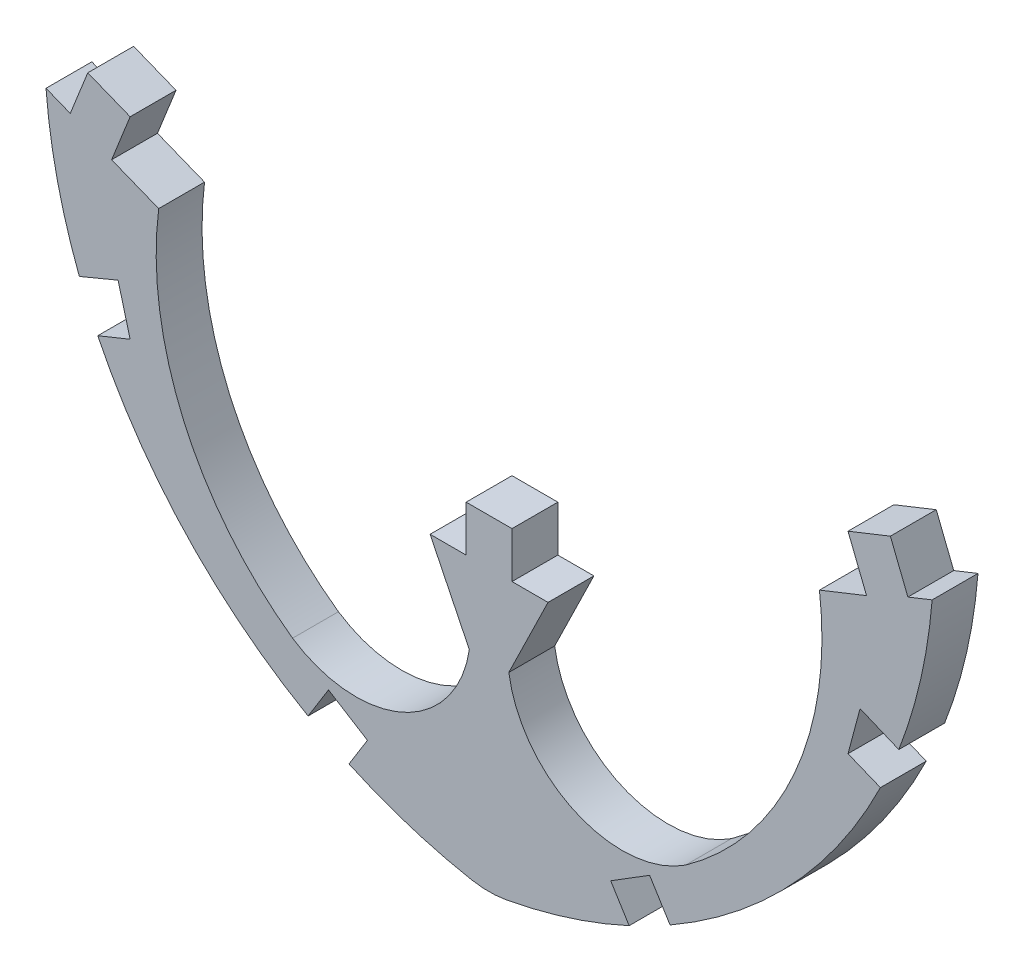
from build123d import *

# Parameters (mm, degrees)
BOSS_EXTRUDE1_DEPTH = 1.524


with BuildPart() as part:
    # Sketch1 → Boss-Extrude1 (new body)
    with BuildSketch(Plane.XY):
        with BuildLine():
            Line((106.800157748, 0), (106.800157748, -1.524))
            Line((106.800157748, -1.524), (105.60228421, -1.524))
            Line((105.60228421, -1.524), (106.906721504, -4.193201134))
            ThreePointArc((106.906721504, -4.193201134), (104.68375507, -7.107123849), (101.031549593, -6.800659311))
            ThreePointArc((101.031549593, -6.800659311), (97.409591285, -2.343413311), (96.581327911, 3.339860717))
            Line((96.581327911, 3.339860717), (95.016948104, 3.963243569))
            Line((95.016948104, 3.963243569), (95.633020179, 5.509276977))
            Line((95.633020179, 5.509276977), (94.224893193, 6.070395327))
            Line((94.224893193, 6.070395327), (93.642665079, 4.609293369))
            Line((93.642665079, 4.609293369), (92.836519037, 4.930530972))
            ThreePointArc((92.836519037, 4.930530972), (93.215521974, 2.459616544), (93.944606865, 0.068487824))
            Line((93.944606865, 0.068487824), (95.231857751, 0.60397688))
            Line((95.231857751, 0.60397688), (95.633020179, -0.895095706))
            Line((95.633020179, -0.895095706), (94.556110103, -1.331762333))
            ThreePointArc((94.556110103, -1.331762333), (97.492489487, -5.581662211), (101.546965864, -8.782473698))
            Line((101.546965864, -8.782473698), (102.225393513, -7.690984294))
            Line((102.225393513, -7.690984294), (103.519739314, -8.495499643))
            Line((103.519739314, -8.495499643), (102.906411146, -9.482253643))
            ThreePointArc((102.906411146, -9.482253643), (104.901784449, -10.255997053), (106.977037338, -10.77898742))
            ThreePointArc((106.977037338, -10.77898742), (107.562157749, -10.833369035), (108.14727816, -10.77898742))
            ThreePointArc((108.14727816, -10.77898742), (110.222531049, -10.255997053), (112.217904351, -9.482253643))
            Line((112.217904351, -9.482253643), (111.604576184, -8.495499643))
            Line((111.604576184, -8.495499643), (112.898921985, -7.690984294))
            Line((112.898921985, -7.690984294), (113.577349634, -8.782473698))
            ThreePointArc((113.577349634, -8.782473698), (117.631826011, -5.581662211), (120.568205395, -1.331762333))
            Line((120.568205395, -1.331762333), (119.491295318, -0.895095706))
            Line((119.491295318, -0.895095706), (119.892457747, 0.60397688))
            Line((119.892457747, 0.60397688), (121.179708632, 0.068487824))
            ThreePointArc((121.179708632, 0.068487824), (121.908793523, 2.459616544), (122.287796461, 4.930530972))
            Line((122.287796461, 4.930530972), (121.481650419, 4.609293369))
            Line((121.481650419, 4.609293369), (120.899422305, 6.070395327))
            Line((120.899422305, 6.070395327), (119.491295318, 5.509276977))
            Line((119.491295318, 5.509276977), (120.107367394, 3.963243569))
            Line((120.107367394, 3.963243569), (118.542987586, 3.339860717))
            ThreePointArc((118.542987586, 3.339860717), (117.714724213, -2.343413311), (114.092765904, -6.800659311))
            ThreePointArc((114.092765904, -6.800659311), (110.440560427, -7.107123849), (108.217593993, -4.193201134))
            Line((108.217593993, -4.193201134), (109.522031288, -1.524))
            Line((109.522031288, -1.524), (108.32415775, -1.524))
            Line((108.32415775, -1.524), (108.32415775, 0))
            Line((108.32415775, 0), (106.800157748, 0))
        make_face()
    extrude(amount=BOSS_EXTRUDE1_DEPTH)


solid = part.part
